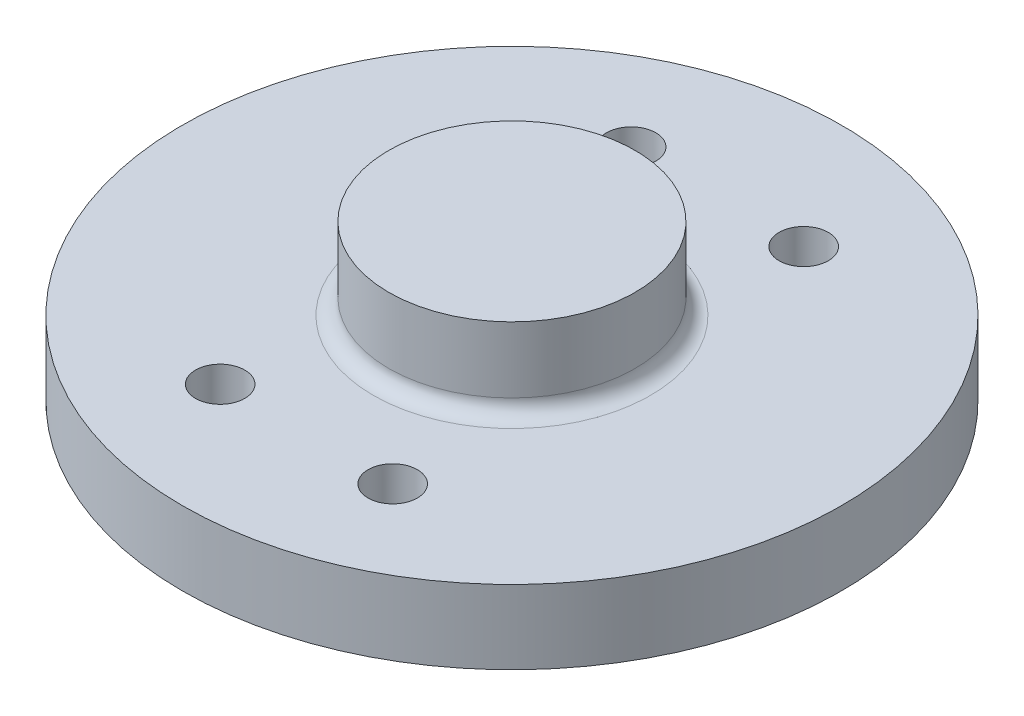
from build123d import *

# Parameters (mm, degrees)
CROQUIS1_R              = 85
SALIENTE_EXTRUIR1_DEPTH = 19.05
CROQUIS2_R              = 31.75
SALIENTE_EXTRUIR2_DEPTH = 21
REDONDEO1_R             = 4
CROQUIS3_R              = 6.35
CORTAR_EXTRUIR1_DEPTH   = 19.05


with BuildPart() as part:
    # Croquis1 → Saliente-Extruir1 (new body)
    with BuildSketch(Plane(origin=(0, 0, 0), x_dir=(1, 0, 0), z_dir=(0, 1, 0))):
        Circle(CROQUIS1_R)
    extrude(amount=SALIENTE_EXTRUIR1_DEPTH)

    # Croquis2 → Saliente-Extruir2 (add)
    with BuildSketch(Plane(origin=(0, 19.05, 0), x_dir=(1, 0, 0), z_dir=(0, 1, 0))):
        Circle(CROQUIS2_R)
    extrude(amount=SALIENTE_EXTRUIR2_DEPTH)

    # Redondeo1
    redondeo1_edges = [part.edges().sort_by_distance(p)[0] for p in [
        (-31.75, 19.05, 0),
    ]]
    fillet(redondeo1_edges, radius=REDONDEO1_R)

    # Croquis3 → Cortar-Extruir1 (cut)
    with BuildSketch(Plane(origin=(0, 19.05, 0), x_dir=(1, 0, 0), z_dir=(0, 1, 0))):
        with Locations((-22.25, -53)):
            Circle(CROQUIS3_R)
        with Locations((-22.25, 53)):
            Circle(CROQUIS3_R)
        with Locations((22.25, 53)):
            Circle(CROQUIS3_R)
        with Locations((22.25, -53)):
            Circle(CROQUIS3_R)
    extrude(amount=-CORTAR_EXTRUIR1_DEPTH, mode=Mode.SUBTRACT)


solid = part.part
